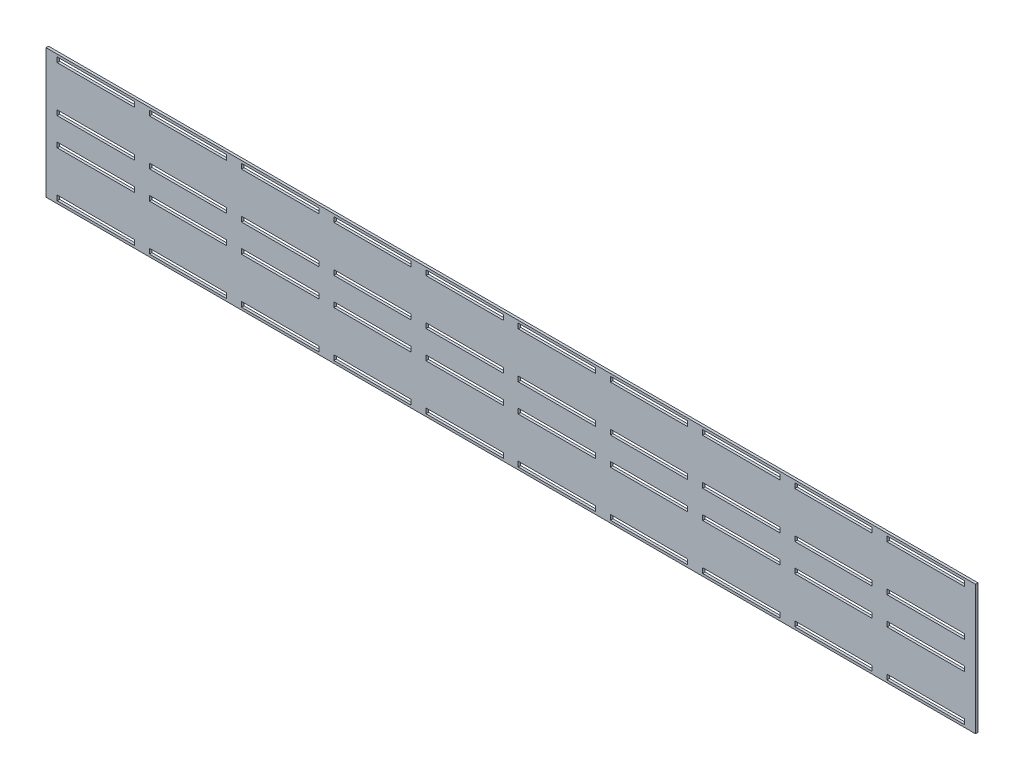
from build123d import *

# Parameters (mm, degrees)
SZKIC1_W                    = 374
SZKIC1_H                    = 53
DODANIE_WYCI_GNI_CIE1_DEPTH = 1
SZKIC6_W                    = 31
SZKIC6_H                    = 2
WYTNIJ_WYCI_GNI_CIE1_DEPTH  = 2
SZKIC7_W                    = 374
SZKIC7_H                    = 53
SZKIC7_W_2                  = 373
SZKIC7_H_2                  = 52
WYTNIJ_WYCI_GNI_CIE2_DEPTH  = 10


with BuildPart() as part:
    # Szkic1 → Dodanie-wyciągnięcie1 (new body)
    with BuildSketch(Plane.XY):
        Rectangle(SZKIC1_W, SZKIC1_H)
    extrude(amount=DODANIE_WYCI_GNI_CIE1_DEPTH)

    # Szkic6 → Wytnij-wyciągnięcie1 (cut)
    with BuildSketch(Plane(origin=(0, 0, 0), x_dir=(-1, 0, 0), z_dir=(0, 0, -1))):
        with Locations((-166.5, -5.6)):
            Rectangle(SZKIC6_W, SZKIC6_H)
        with Locations((-129.5, -5.6)):
            Rectangle(SZKIC6_W, SZKIC6_H)
        with Locations((-92.5, -5.6)):
            Rectangle(SZKIC6_W, SZKIC6_H)
        with Locations((-18.5, -5.6)):
            Rectangle(SZKIC6_W, SZKIC6_H)
        with Locations((18.5, -5.6)):
            Rectangle(SZKIC6_W, SZKIC6_H)
        with Locations((55.5, -5.6)):
            Rectangle(SZKIC6_W, SZKIC6_H)
        with Locations((92.5, -5.6)):
            Rectangle(SZKIC6_W, SZKIC6_H)
        with Locations((129.5, -5.6)):
            Rectangle(SZKIC6_W, SZKIC6_H)
        with Locations((166.5, -5.6)):
            Rectangle(SZKIC6_W, SZKIC6_H)
        with Locations((-129.5, -24)):
            Rectangle(SZKIC6_W, SZKIC6_H)
        with Locations((-166.5, 24)):
            Rectangle(SZKIC6_W, SZKIC6_H)
        with Locations((-166.5, -24)):
            Rectangle(SZKIC6_W, SZKIC6_H)
        with Locations((-129.5, 24)):
            Rectangle(SZKIC6_W, SZKIC6_H)
        with Locations((-92.5, -24)):
            Rectangle(SZKIC6_W, SZKIC6_H)
        with Locations((-92.5, 24)):
            Rectangle(SZKIC6_W, SZKIC6_H)
        with Locations((-55.5, -24)):
            Rectangle(SZKIC6_W, SZKIC6_H)
        with Locations((-55.5, 24)):
            Rectangle(SZKIC6_W, SZKIC6_H)
        with Locations((-18.5, -24)):
            Rectangle(SZKIC6_W, SZKIC6_H)
        with Locations((-18.5, 24)):
            Rectangle(SZKIC6_W, SZKIC6_H)
        with Locations((18.5, -24)):
            Rectangle(SZKIC6_W, SZKIC6_H)
        with Locations((18.5, 24)):
            Rectangle(SZKIC6_W, SZKIC6_H)
        with Locations((55.5, -24)):
            Rectangle(SZKIC6_W, SZKIC6_H)
        with Locations((55.5, 24)):
            Rectangle(SZKIC6_W, SZKIC6_H)
        with Locations((92.5, -24)):
            Rectangle(SZKIC6_W, SZKIC6_H)
        with Locations((92.5, 24)):
            Rectangle(SZKIC6_W, SZKIC6_H)
        with Locations((129.5, -24)):
            Rectangle(SZKIC6_W, SZKIC6_H)
        with Locations((129.5, 24)):
            Rectangle(SZKIC6_W, SZKIC6_H)
        with Locations((166.5, -24)):
            Rectangle(SZKIC6_W, SZKIC6_H)
        with Locations((166.5, 24)):
            Rectangle(SZKIC6_W, SZKIC6_H)
        with Locations((-129.5, 5.6)):
            Rectangle(SZKIC6_W, SZKIC6_H)
        with Locations((-55.5, -5.6)):
            Rectangle(SZKIC6_W, SZKIC6_H)
        with Locations((-166.5, 5.6)):
            Rectangle(SZKIC6_W, SZKIC6_H)
        with Locations((-92.5, 5.6)):
            Rectangle(SZKIC6_W, SZKIC6_H)
        with Locations((-55.5, 5.6)):
            Rectangle(SZKIC6_W, SZKIC6_H)
        with Locations((-18.5, 5.6)):
            Rectangle(SZKIC6_W, SZKIC6_H)
        with Locations((18.5, 5.6)):
            Rectangle(SZKIC6_W, SZKIC6_H)
        with Locations((55.5, 5.6)):
            Rectangle(SZKIC6_W, SZKIC6_H)
        with Locations((92.5, 5.6)):
            Rectangle(SZKIC6_W, SZKIC6_H)
        with Locations((129.5, 5.6)):
            Rectangle(SZKIC6_W, SZKIC6_H)
        with Locations((166.5, 5.6)):
            Rectangle(SZKIC6_W, SZKIC6_H)
    extrude(amount=-WYTNIJ_WYCI_GNI_CIE1_DEPTH, mode=Mode.SUBTRACT)

    # Szkic7 → Wytnij-wyciągnięcie2 (cut)
    with BuildSketch(Plane(origin=(0, 0, 0), x_dir=(-1, 0, 0), z_dir=(0, 0, -1))):
        Rectangle(SZKIC7_W, SZKIC7_H)
        Rectangle(SZKIC7_W_2, SZKIC7_H_2, mode=Mode.SUBTRACT)
    extrude(amount=-WYTNIJ_WYCI_GNI_CIE2_DEPTH, mode=Mode.SUBTRACT)


solid = part.part
